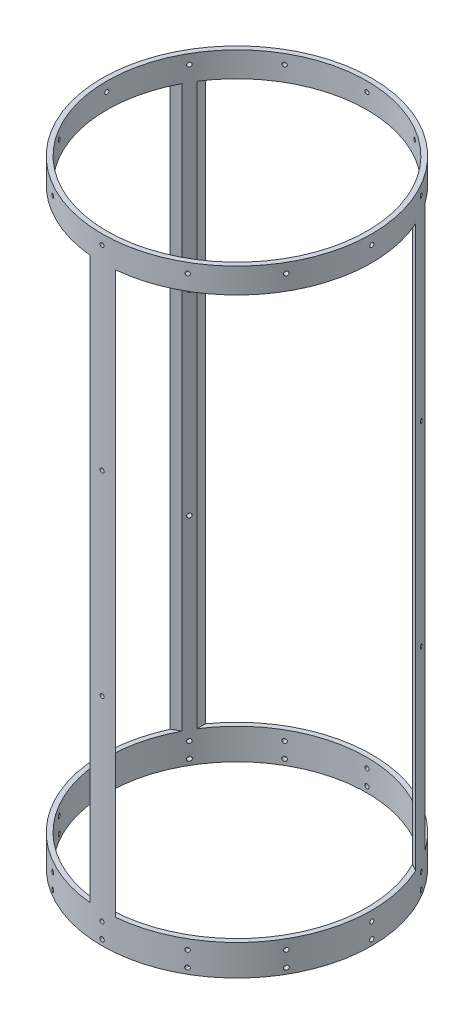
from build123d import *

# Parameters (mm, degrees)
SKETCH1_R           = 88.9
SKETCH1_R_2         = 85.725
BOSS_EXTRUDE1_DEPTH = 203.2
CUT_EXTRUDE1_START  = -88.9
SKETCH2_W           = 144.78
SKETCH2_H           = 369.57
CUT_EXTRUDE1_DEPTH  = 42.981991
CIRPATTERN1_COUNT   = 3
SKETCH3_R           = 1.4351
SKETCH3_R_2         = 1.35255
CUT_EXTRUDE2_DEPTH  = 15.24
CIRPATTERN2_COUNT   = 12
SKETCH4_R           = 1.35255
CUT_EXTRUDE3_DEPTH  = 15.24
CIRPATTERN3_COUNT   = 12
SKETCH5_R           = 1.35255
CUT_EXTRUDE4_DEPTH  = 35.56
CIRPATTERN4_COUNT   = 3


with BuildPart() as part:
    # Sketch1 → Boss-Extrude1 (new body, symmetric)
    with BuildSketch(Plane(origin=(0, 0, 0), x_dir=(1, 0, 0), z_dir=(0, 1, 0))):
        Circle(SKETCH1_R)
        Circle(SKETCH1_R_2, mode=Mode.SUBTRACT)
    extrude(amount=BOSS_EXTRUDE1_DEPTH, both=True)

    # Sketch2 → Cut-Extrude1 (cut)
    with BuildSketch(Plane.XY.offset(CUT_EXTRUDE1_START)):
        with Locations((0, 1.905)):
            Rectangle(SKETCH2_W, SKETCH2_H)
    cut_extrude1 = extrude(amount=CUT_EXTRUDE1_DEPTH, mode=Mode.SUBTRACT)

    # CirPattern1: Cut-Extrude1 ×3 about axis
    cirpattern1_axis = Axis((0, 0, 0), (0, 1, 0))
    for i in range(1, CIRPATTERN1_COUNT):
        add(cut_extrude1.rotate(cirpattern1_axis, i * 360 / CIRPATTERN1_COUNT), mode=Mode.SUBTRACT)

    # Sketch3 → Cut-Extrude2 (cut)
    with BuildSketch(Plane(origin=(88.9, 0, 0), x_dir=(0, 0, -1), z_dir=(1, 0, 0))):
        with Locations((0, -199.39)):
            Circle(SKETCH3_R)
        with Locations((0, -189.23)):
            Circle(SKETCH3_R_2)
    cut_extrude2 = extrude(amount=-CUT_EXTRUDE2_DEPTH, mode=Mode.SUBTRACT)

    # CirPattern2: Cut-Extrude2 ×12 about axis
    cirpattern2_axis = Axis((0, 203.2, 0), (0, -1, 0))
    for i in range(1, CIRPATTERN2_COUNT):
        add(cut_extrude2.rotate(cirpattern2_axis, i * 360 / CIRPATTERN2_COUNT), mode=Mode.SUBTRACT)

    # Sketch4 → Cut-Extrude3 (cut)
    with BuildSketch(Plane(origin=(88.9, 0, 0), x_dir=(0, 0, -1), z_dir=(1, 0, 0))):
        with Locations((0, 196.85)):
            Circle(SKETCH4_R)
    cut_extrude3 = extrude(amount=-CUT_EXTRUDE3_DEPTH, mode=Mode.SUBTRACT)

    # CirPattern3: Cut-Extrude3 ×12 about axis
    cirpattern3_axis = Axis((0, 203.2, 0), (0, -1, 0))
    for i in range(1, CIRPATTERN3_COUNT):
        add(cut_extrude3.rotate(cirpattern3_axis, i * 360 / CIRPATTERN3_COUNT), mode=Mode.SUBTRACT)

    # Sketch5 → Cut-Extrude4 (cut)
    with BuildSketch(Plane.XY.offset(88.9)):
        with Locations((0, 68.1736)):
            Circle(SKETCH5_R)
        with Locations((0, -60.5536)):
            Circle(SKETCH5_R)
    cut_extrude4 = extrude(amount=-CUT_EXTRUDE4_DEPTH, mode=Mode.SUBTRACT)

    # CirPattern4: Cut-Extrude4 ×3 about axis
    cirpattern4_axis = Axis((0, 203.2, 0), (0, -1, 0))
    for i in range(1, CIRPATTERN4_COUNT):
        add(cut_extrude4.rotate(cirpattern4_axis, i * 360 / CIRPATTERN4_COUNT), mode=Mode.SUBTRACT)


solid = part.part
